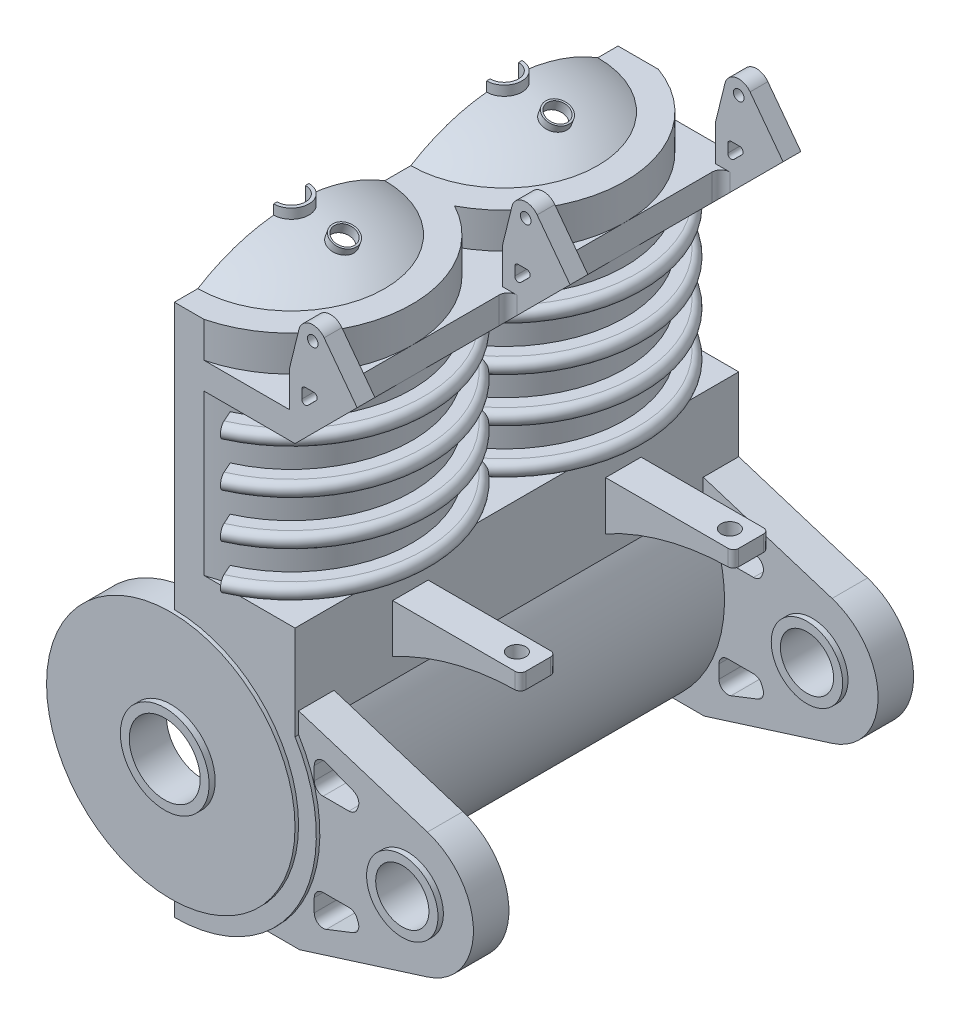
from build123d import *

# Parameters (mm, degrees)
BOSS_EXTRUDE1_DEPTH  = 25
SKETCH2_R            = 5
CUT_EXTRUDE1_DEPTH   = 20
SKETCH4_R            = 7
CUT_EXTRUDE2_DEPTH   = 41.971588864
CUT_EXTRUDE3_DEPTH   = 9
SKETCH6_W            = 0.505
SKETCH6_H            = 10
REVOLVE1_ANGLE       = 156
LPATTERN1_COUNT      = 2
LPATTERN1_PITCH      = 12
SKETCH7_R            = 5
CUT_EXTRUDE4_DEPTH   = 15
BOSS_EXTRUDE2_START  = -1
SKETCH8_R            = 7
SKETCH8_R_2          = 2.5
BOSS_EXTRUDE2_DEPTH  = 1.5
LPATTERN2_COUNT      = 3
LPATTERN2_PITCH      = 12
BOSS_EXTRUDE3_START  = 0.2
SKETCH10_R           = 7
SKETCH10_R_2         = 2.5
BOSS_EXTRUDE3_DEPTH  = 0.2
BOSS_EXTRUDE4_START  = -1.6
SKETCH11_R           = 2.5
SKETCH11_R_2         = 2
BOSS_EXTRUDE4_DEPTH  = 2.1
LPATTERN3_COUNT      = 3
LPATTERN3_PITCH      = 12.22
BOSS_EXTRUDE5_START  = 2
BOSS_EXTRUDE5_DEPTH  = 2
SKETCH15_R           = 2.013
BOSS_EXTRUDE6_DEPTH  = 2
LPATTERN4_COUNT      = 2
LPATTERN4_PITCH      = 22.8
BOSS_EXTRUDE7_START  = 0.3
SKETCH16_R           = 2.013
SKETCH16_R_2         = 1.5
BOSS_EXTRUDE7_DEPTH  = 2.6
LPATTERN5_COUNT      = 2
LPATTERN5_PITCH      = 22.8
CUT_EXTRUDE5_DEPTH   = 47.695982756
REVOLVE2_ANGLE       = 180
LPATTERN6_COUNT      = 2
LPATTERN6_PITCH      = 12
SKETCH19_R           = 0.995
CUT_EXTRUDE6_DEPTH   = 10
BOSS_EXTRUDE8_START  = 1.2
BOSS_EXTRUDE8_DEPTH  = 0.8
SKETCH21_R           = 0.6
CUT_EXTRUDE7_DEPTH   = 49.01575031
SKETCH22_R           = 0.3
BOSS_EXTRUDE9_DEPTH  = 1
LPATTERN7_COUNT      = 3
LPATTERN7_PITCH      = 12
FILLET1_R            = 0.5
BOSS_EXTRUDE10_START = -5.5
BOSS_EXTRUDE10_DEPTH = 2
LPATTERN8_COUNT      = 2
LPATTERN8_PITCH      = 12
SKETCH24_R           = 0.5
CUT_EXTRUDE8_DEPTH   = 2
FILLET2_R            = 0.3
SKETCH25_W           = 4.731250972
SKETCH25_H           = 3.504290533
CUT_EXTRUDE9_DEPTH   = 48.773551565
SKETCH26_R           = 0.3
BOSS_EXTRUDE11_DEPTH = 1
LPATTERN9_COUNT      = 3
LPATTERN9_PITCH      = 12
EXTRUDE_THIN1_START  = 1.9
SKETCH21_2_R         = 0.7
SKETCH21_2_R_2       = 0.6
EXTRUDE_THIN1_DEPTH  = 0.5


with BuildPart() as part:
    # Sketch1 → Boss-Extrude1 (new body)
    with BuildSketch(Plane.XY):
        with BuildLine():
            Line((-23.445628982, 22.449355796), (-23.445628982, -5.570644204))
            ThreePointArc((-23.445628982, -5.570644204), (-16.45584744, -1.462039069), (-16.645628982, 6.643617297))
            Line((-16.645628982, 6.643617297), (-16.645628982, 22.449355796))
            Line((-16.645628982, 22.449355796), (-23.445628982, 22.449355796))
        make_face()
    extrude(amount=BOSS_EXTRUDE1_DEPTH)

    # Sketch2 → Cut-Extrude1 (cut)
    with BuildSketch(Plane(origin=(0, 22.449355796, 0), x_dir=(1, 0, 0), z_dir=(0, 1, 0))):
        with Locations((-23.445628982, -6.41)):
            Circle(SKETCH2_R)
        with Locations((-23.445628982, -18.41)):
            Circle(SKETCH2_R)
    extrude(amount=-CUT_EXTRUDE1_DEPTH, mode=Mode.SUBTRACT)

    # Sketch4 → Cut-Extrude2 (cut, through all)
    with BuildSketch(Plane.XY.offset(25)):
        with Locations((-23.445628982, 2.449355796)):
            Circle(SKETCH4_R)
    extrude(amount=-CUT_EXTRUDE2_DEPTH, mode=Mode.SUBTRACT)

    # Sketch5 → Cut-Extrude3 (cut)
    with BuildSketch(Plane(origin=(0, 20.949355796, 0), x_dir=(1, 0, 0), z_dir=(0, 1, 0))):
        with BuildLine():
            Line((-23.445628982, 0.39), (-14.591796917, 0.39))
            Line((-14.591796917, 0.39), (-14.591796917, -25.21))
            Line((-14.591796917, -25.21), (-23.445628982, -25.21))
            ThreePointArc((-23.445628982, -25.21), (-16.848659981, -20.05924225), (-20.245628982, -12.41))
            ThreePointArc((-20.245628982, -12.41), (-16.848659981, -4.76075775), (-23.445628982, 0.39))
        make_face()
    extrude(amount=-CUT_EXTRUDE3_DEPTH, mode=Mode.SUBTRACT)

    # Sketch6 → Revolve1 (revolve)
    with BuildSketch(Plane.ZY.offset(23.445628982)):
        with Locations((0.4275, 16.599355796)):
            Rectangle(SKETCH6_W, SKETCH6_H)
        with BuildLine():
            Line((0, 19.499355796), (0, 20.299355796))
            Line((0, 20.299355796), (-1.07, 20.299355796))
            ThreePointArc((-1.07, 20.299355796), (-1.47, 19.899355796), (-1.07, 19.499355796))
            Line((-1.07, 19.499355796), (0, 19.499355796))
        make_face()
        with BuildLine():
            Line((-1.07, 11.999355796), (0, 11.999355796))
            Line((0, 11.999355796), (0, 12.799355796))
            Line((0, 12.799355796), (-1.07, 12.799355796))
            ThreePointArc((-1.07, 12.799355796), (-1.47, 12.399355796), (-1.07, 11.999355796))
        make_face()
        with BuildLine():
            Line((0, 16.999355796), (0, 17.799355796))
            Line((0, 17.799355796), (-1.07, 17.799355796))
            ThreePointArc((-1.07, 17.799355796), (-1.47, 17.399355796), (-1.07, 16.999355796))
            Line((-1.07, 16.999355796), (0, 16.999355796))
        make_face()
        with BuildLine():
            Line((-1.07, 14.499355796), (0, 14.499355796))
            Line((0, 14.499355796), (0, 15.299355796))
            Line((0, 15.299355796), (-1.07, 15.299355796))
            ThreePointArc((-1.07, 15.299355796), (-1.47, 14.899355796), (-1.07, 14.499355796))
        make_face()
    revolve1 = revolve(axis=Axis((-23.445628982, 22.449355796, 6.41), (0, -1, 0)), revolution_arc=REVOLVE1_ANGLE)

    # LPattern1: Revolve1 ×2
    with Locations(*[(0, 0, i * LPATTERN1_PITCH) for i in range(1, LPATTERN1_COUNT)]):
        add(revolve1)

    # Sketch7 → Cut-Extrude4 (cut)
    with BuildSketch(Plane(origin=(0, 22.449355796, 0), x_dir=(1, 0, 0), z_dir=(0, 1, 0))):
        with Locations((-23.445628982, -6.41)):
            Circle(SKETCH7_R)
    extrude(amount=-CUT_EXTRUDE4_DEPTH, mode=Mode.SUBTRACT)

    # Sketch8 → Boss-Extrude2 (add)
    with BuildSketch(Plane(origin=(0, 0, 0), x_dir=(-1, 0, 0), z_dir=(0, 0, -1)).offset(BOSS_EXTRUDE2_START)):
        with Locations((23.445628982, 2.429355796)):
            Circle(SKETCH8_R)
        with Locations((23.445628982, 2.429355796)):
            Circle(SKETCH8_R_2, mode=Mode.SUBTRACT)
    boss_extrude2 = extrude(amount=BOSS_EXTRUDE2_DEPTH)

    # LPattern2: Boss-Extrude2 ×3
    with Locations(*[(0, 0, i * LPATTERN2_PITCH) for i in range(1, LPATTERN2_COUNT)]):
        add(boss_extrude2)

    # Sketch10 → Boss-Extrude3 (add)
    with BuildSketch(Plane.XY.offset(25).offset(BOSS_EXTRUDE3_START)):
        with Locations((-23.445628982, 2.429355796)):
            Circle(SKETCH10_R)
        with Locations((-23.445628982, 2.429355796)):
            Circle(SKETCH10_R_2, mode=Mode.SUBTRACT)
    extrude(amount=-BOSS_EXTRUDE3_DEPTH)

    # Sketch11 → Boss-Extrude4 (add)
    with BuildSketch(Plane(origin=(0, 0, -0.5), x_dir=(-1, 0, 0), z_dir=(0, 0, -1)).offset(BOSS_EXTRUDE4_START)):
        with Locations((23.445628982, 2.429355796)):
            Circle(SKETCH11_R)
        with Locations((23.445628982, 2.429355796)):
            Circle(SKETCH11_R_2, mode=Mode.SUBTRACT)
    boss_extrude4 = extrude(amount=BOSS_EXTRUDE4_DEPTH)

    # LPattern3: Boss-Extrude4 ×3
    with Locations(*[(0, 0, i * LPATTERN3_PITCH) for i in range(1, LPATTERN3_COUNT)]):
        add(boss_extrude4)

    # Sketch14 → Boss-Extrude5 (add)
    with BuildSketch(Plane(origin=(0, 22.449355796, 0), x_dir=(1, 0, 0), z_dir=(0, 1, 0)).offset(BOSS_EXTRUDE5_START)):
        with BuildLine():
            Line((-23.445628982, -13.41), (-23.445628982, -11.41))
            ThreePointArc((-23.445628982, -11.41), (-18.445628982, -6.41), (-23.445628982, -1.41))
            Line((-23.445628982, -1.41), (-23.445628982, 0))
            Line((-23.445628982, 0), (-21.175849257, 0))
            ThreePointArc((-21.175849257, 0), (-17.892499138, -2.485366395), (-16.645628982, -6.41))
            ThreePointArc((-16.645628982, -6.41), (-17.614677088, -9.908571137), (-20.245628982, -12.41))
            ThreePointArc((-20.245628982, -12.41), (-17.614677088, -14.911428863), (-16.645628982, -18.41))
            ThreePointArc((-16.645628982, -18.41), (-18.07707563, -22.583563813), (-21.768756894, -25))
            Line((-21.768756894, -25), (-23.445628982, -25))
            Line((-23.445628982, -25), (-23.445628982, -23.41))
            ThreePointArc((-23.445628982, -23.41), (-18.445628982, -18.41), (-23.445628982, -13.41))
        make_face()
    extrude(amount=-BOSS_EXTRUDE5_DEPTH)

    # Sketch15 → Boss-Extrude6 (add)
    with BuildSketch(Plane(origin=(0, 0, 0), x_dir=(-1, 0, 0), z_dir=(0, 0, -1))):
        with BuildLine():
            Line((16.645628982, 7.810949022), (9.386912584, 5.522284533))
            ThreePointArc((9.386912584, 5.522284533), (6.794628982, 1.986855796), (9.386912584, -1.54857294))
            Line((9.386912584, -1.54857294), (16.591153556, -3.820061393))
            Line((16.591153556, -3.820061393), (18.451153556, -3.820061393))
            ThreePointArc((18.451153556, -3.820061393), (15.562130039, 1.069045385), (16.645628982, 6.643617297))
            Line((16.645628982, 6.643617297), (16.645628982, 7.810949022))
        make_face()
        with Locations((10.501628982, 1.986855796)):
            Circle(SKETCH15_R, mode=Mode.SUBTRACT)
    boss_extrude6 = extrude(amount=-BOSS_EXTRUDE6_DEPTH)

    # LPattern4: Boss-Extrude6 ×2
    with Locations(*[(0, 0, i * LPATTERN4_PITCH) for i in range(1, LPATTERN4_COUNT)]):
        add(boss_extrude6)

    # Sketch16 → Boss-Extrude7 (add)
    with BuildSketch(Plane(origin=(0, 0, 0), x_dir=(-1, 0, 0), z_dir=(0, 0, -1)).offset(BOSS_EXTRUDE7_START)):
        with Locations((10.501628982, 1.986855796)):
            Circle(SKETCH16_R)
        with Locations((10.501628982, 1.986855796)):
            Circle(SKETCH16_R_2, mode=Mode.SUBTRACT)
    boss_extrude7 = extrude(amount=-BOSS_EXTRUDE7_DEPTH)

    # LPattern5: Boss-Extrude7 ×2
    with Locations(*[(0, 0, i * LPATTERN5_PITCH) for i in range(1, LPATTERN5_COUNT)]):
        add(boss_extrude7)

    # Sketch17 → Cut-Extrude5 (cut, through all)
    with BuildSketch(Plane(origin=(0, 0, 0), x_dir=(-1, 0, 0), z_dir=(0, 0, -1))):
        with BuildLine():
            Line((13.569096445, 5.452925663), (15.08058071, 6.045264091))
            ThreePointArc((15.08058071, 6.045264091), (15.544781268, 5.992784259), (15.763017559, 5.579735579))
            Line((15.763017559, 5.579735579), (15.763017559, 4.836087593))
            ThreePointArc((15.763017559, 4.836087593), (15.61657095, 4.482534203), (15.263017559, 4.336087593))
            Line((15.263017559, 4.336087593), (13.810830283, 4.336087593))
            ThreePointArc((13.810830283, 4.336087593), (13.529066574, 4.423038913), (13.34530177, 4.653650744))
            Line((13.34530177, 4.653650744), (13.286004782, 4.804960301))
            ThreePointArc((13.286004782, 4.804960301), (13.293352593, 5.187573185), (13.569096445, 5.452925663))
        make_face()
        with BuildLine():
            Line((15.263017559, -0.362376001), (13.810830283, -0.362376001))
            ThreePointArc((13.810830283, -0.362376001), (13.529066574, -0.449327321), (13.34530177, -0.679939151))
            Line((13.34530177, -0.679939151), (13.286004782, -0.831248709))
            ThreePointArc((13.286004782, -0.831248709), (13.293352593, -1.213861593), (13.569096445, -1.479214071))
            Line((13.569096445, -1.479214071), (15.08058071, -2.071552499))
            ThreePointArc((15.08058071, -2.071552499), (15.544781268, -2.019072667), (15.763017559, -1.606023986))
            Line((15.763017559, -1.606023986), (15.763017559, -0.862376001))
            ThreePointArc((15.763017559, -0.862376001), (15.61657095, -0.50882261), (15.263017559, -0.362376001))
        make_face()
    extrude(amount=-CUT_EXTRUDE5_DEPTH, mode=Mode.SUBTRACT)

    # Sketch18 → Revolve2 (revolve)
    with BuildSketch(Plane.ZY.offset(23.445628982)):
        with BuildLine():
            Line((18.41, 25.949355796), (18.41, 25.829355796))
            ThreePointArc((18.41, 25.829355796), (15.799023171, 25.478112273), (13.373691828, 24.449355796))
            Line((13.373691828, 24.449355796), (13.142173124, 24.449355796))
            ThreePointArc((13.142173124, 24.449355796), (15.671387212, 25.567047827), (18.41, 25.949355796))
        make_face()
    revolve2 = revolve(axis=Axis((-23.445628982, 24.449355796, 18.41), (0, -1, 0)), revolution_arc=REVOLVE2_ANGLE)

    # LPattern6: Revolve2 ×2
    with Locations(*[(0, 0, -i * LPATTERN6_PITCH) for i in range(1, LPATTERN6_COUNT)]):
        add(revolve2)

    # Sketch19 → Cut-Extrude6 (cut)
    with BuildSketch(Plane(origin=(0, 24.449355796, 0), x_dir=(1, 0, 0), z_dir=(0, 1, 0))):
        with Locations((-23.445628982, -6.41)):
            Circle(SKETCH19_R)
        with Locations((-23.445628982, -18.41)):
            Circle(SKETCH19_R)
    extrude(amount=CUT_EXTRUDE6_DEPTH, mode=Mode.SUBTRACT)

    # Sketch20 → Boss-Extrude8 (add)
    with BuildSketch(Plane(origin=(0, 24.449355796, 0), x_dir=(1, 0, 0), z_dir=(0, 1, 0)).offset(BOSS_EXTRUDE8_START)):
        with BuildLine():
            Line((-23.445628982, -17.415), (-23.445628982, -17.61))
            ThreePointArc((-23.445628982, -17.61), (-22.645628982, -18.41), (-23.445628982, -19.21))
            Line((-23.445628982, -19.21), (-23.445628982, -19.405))
            ThreePointArc((-23.445628982, -19.405), (-22.450628982, -18.41), (-23.445628982, -17.415))
        make_face()
        with BuildLine():
            Line((-23.445628982, -5.415), (-23.445628982, -5.61))
            ThreePointArc((-23.445628982, -5.61), (-22.645628982, -6.41), (-23.445628982, -7.21))
            Line((-23.445628982, -7.21), (-23.445628982, -7.405))
            ThreePointArc((-23.445628982, -7.405), (-22.450628982, -6.41), (-23.445628982, -5.415))
        make_face()
    extrude(amount=BOSS_EXTRUDE8_DEPTH)

    # Sketch21 → Cut-Extrude7 (cut, through all)
    with BuildSketch(Plane(origin=(5.115253893, 14.054044565, 0), x_dir=(0, 0, 1), z_dir=(0.34202014332565694, 0.9396926207859128, -1.0769731036982655e-14))):
        with Locations((6.41, -28.077897005)):
            Circle(SKETCH21_R)
        with Locations((18.41, -28.077897005)):
            Circle(SKETCH21_R)
    extrude(amount=CUT_EXTRUDE7_DEPTH, mode=Mode.SUBTRACT)

    # Sketch22 → Boss-Extrude9 (add)
    with BuildSketch(Plane(origin=(0, 0, 0), x_dir=(-1, 0, 0), z_dir=(0, 0, -1))):
        with BuildLine():
            Line((12.7713292, 24.823655578), (16.645628982, 20.949355796))
            Line((16.645628982, 20.949355796), (16.960628982, 20.949355796))
            Line((16.960628982, 20.949355796), (16.960628982, 24.449355796))
            Line((16.960628982, 24.449355796), (14.645628982, 24.449355796))
            Line((14.645628982, 24.449355796), (13.5213292, 25.573655578))
            ThreePointArc((13.5213292, 25.573655578), (12.7713292, 25.573655578), (12.7713292, 24.823655578))
        make_face()
        with Locations((13.1463292, 25.198655578)):
            Circle(SKETCH22_R, mode=Mode.SUBTRACT)
        with BuildLine():
            Line((15.92256637, 23.172418408), (15.45473515, 23.640249629))
            ThreePointArc((15.45473515, 23.640249629), (15.411380599, 23.858207672), (15.596156506, 23.981670985))
            Line((15.596156506, 23.981670985), (16.063987727, 23.981670985))
            ThreePointArc((16.063987727, 23.981670985), (16.205409083, 23.923092341), (16.263987727, 23.781670985))
            Line((16.263987727, 23.781670985), (16.263987727, 23.313839765))
            ThreePointArc((16.263987727, 23.313839765), (16.140524413, 23.129063858), (15.92256637, 23.172418408))
        make_face(mode=Mode.SUBTRACT)
    boss_extrude9 = extrude(amount=-BOSS_EXTRUDE9_DEPTH)

    # LPattern7: Boss-Extrude9 ×3
    with Locations(*[(0, 0, i * LPATTERN7_PITCH) for i in range(1, LPATTERN7_COUNT)]):
        add(boss_extrude9)

    # Fillet1
    fillet1_edges = [part.edges().sort_by_distance(p)[0] for p in [
        (-16.645628982, 21.699355796, 1),
        (-16.645628982, 21.699355796, 13),
        (-16.645628982, 21.699355796, 24),
        (-16.645628982, 21.699355796, 12),
    ]]
    fillet(fillet1_edges, radius=FILLET1_R)

    # Sketch23 → Boss-Extrude10 (add)
    with BuildSketch(Plane(origin=(0, 0, 0), x_dir=(-1, 0, 0), z_dir=(0, 0, -1)).offset(BOSS_EXTRUDE10_START)):
        with BuildLine():
            Line((16.645628982, 10.539355796), (9.445628982, 10.539355796))
            Line((9.445628982, 10.539355796), (9.445628982, 9.639355796))
            ThreePointArc((9.445628982, 9.639355796), (13.161445865, 9.171826505), (16.645628982, 7.798383116))
            Line((16.645628982, 7.798383116), (16.645628982, 10.539355796))
        make_face()
    boss_extrude10 = extrude(amount=-BOSS_EXTRUDE10_DEPTH)

    # LPattern8: Boss-Extrude10 ×2
    with Locations(*[(0, 0, i * LPATTERN8_PITCH) for i in range(1, LPATTERN8_COUNT)]):
        add(boss_extrude10)

    # Sketch24 → Cut-Extrude8 (cut)
    with BuildSketch(Plane(origin=(0, 10.539355796, 0), x_dir=(1, 0, 0), z_dir=(0, 1, 0))):
        with Locations((-10.645628982, -6.5)):
            Circle(SKETCH24_R)
        with Locations((-10.645628982, -18.5)):
            Circle(SKETCH24_R)
    extrude(amount=-CUT_EXTRUDE8_DEPTH, mode=Mode.SUBTRACT)

    # Fillet2
    fillet2_edges = [part.edges().sort_by_distance(p)[0] for p in [
        (-9.445628982, 10.089355796, 5.5),
        (-9.445628982, 10.089355796, 7.5),
        (-9.445628982, 10.089355796, 17.5),
        (-9.445628982, 10.089355796, 19.5),
    ]]
    fillet(fillet2_edges, radius=FILLET2_R)

    # Sketch25 → Cut-Extrude9 (cut, through all)
    with BuildSketch(Plane(origin=(0, 0, 0), x_dir=(-1, 0, 0), z_dir=(0, 0, -1))):
        with Locations((12.710935125, 26.201501063)):
            Rectangle(SKETCH25_W, SKETCH25_H)
    extrude(amount=-CUT_EXTRUDE9_DEPTH, mode=Mode.SUBTRACT)

    # Sketch26 → Boss-Extrude11 (add)
    with BuildSketch(Plane(origin=(0, 0, 0), x_dir=(-1, 0, 0), z_dir=(0, 0, -1))):
        with BuildLine():
            Line((15.005628982, 26.929355796), (13.145628982, 24.449355796))
            Line((13.145628982, 24.449355796), (16.960628982, 24.449355796))
            Line((16.960628982, 24.449355796), (16.42253855, 26.640173837))
            ThreePointArc((16.42253855, 26.640173837), (15.805605883, 27.233197229), (15.005628982, 26.929355796))
        make_face()
        with Locations((15.645628982, 26.449355796)):
            Circle(SKETCH26_R, mode=Mode.SUBTRACT)
    boss_extrude11 = extrude(amount=-BOSS_EXTRUDE11_DEPTH)

    # LPattern9: Boss-Extrude11 ×3
    with Locations(*[(0, 0, i * LPATTERN9_PITCH) for i in range(1, LPATTERN9_COUNT)]):
        add(boss_extrude11)

    # Sketch21_2 → Extrude-Thin1 (add)
    # profile 1 of 2: a face of its own
    with BuildSketch(Plane(origin=(5.115253893, 14.054044565, 0), x_dir=(0, 0, 1), z_dir=(0.34202014332565694, 0.9396926207859128, -1.0769731036982655e-14)).offset(EXTRUDE_THIN1_START)):
        with Locations((6.41, -28.077897005)):
            Circle(SKETCH21_2_R)
        with Locations((6.41, -28.077897005)):
            Circle(SKETCH21_2_R_2, mode=Mode.SUBTRACT)
    # profile 2 of 2: a face of its own
    with BuildSketch(Plane(origin=(5.115253893, 14.054044565, 0), x_dir=(0, 0, 1), z_dir=(0.34202014332565694, 0.9396926207859128, -1.0769731036982655e-14)).offset(EXTRUDE_THIN1_START)):
        with Locations((18.41, -28.077897005)):
            Circle(SKETCH21_2_R)
        with Locations((18.41, -28.077897005)):
            Circle(SKETCH21_2_R_2, mode=Mode.SUBTRACT)
    extrude(amount=EXTRUDE_THIN1_DEPTH)


solid = part.part
